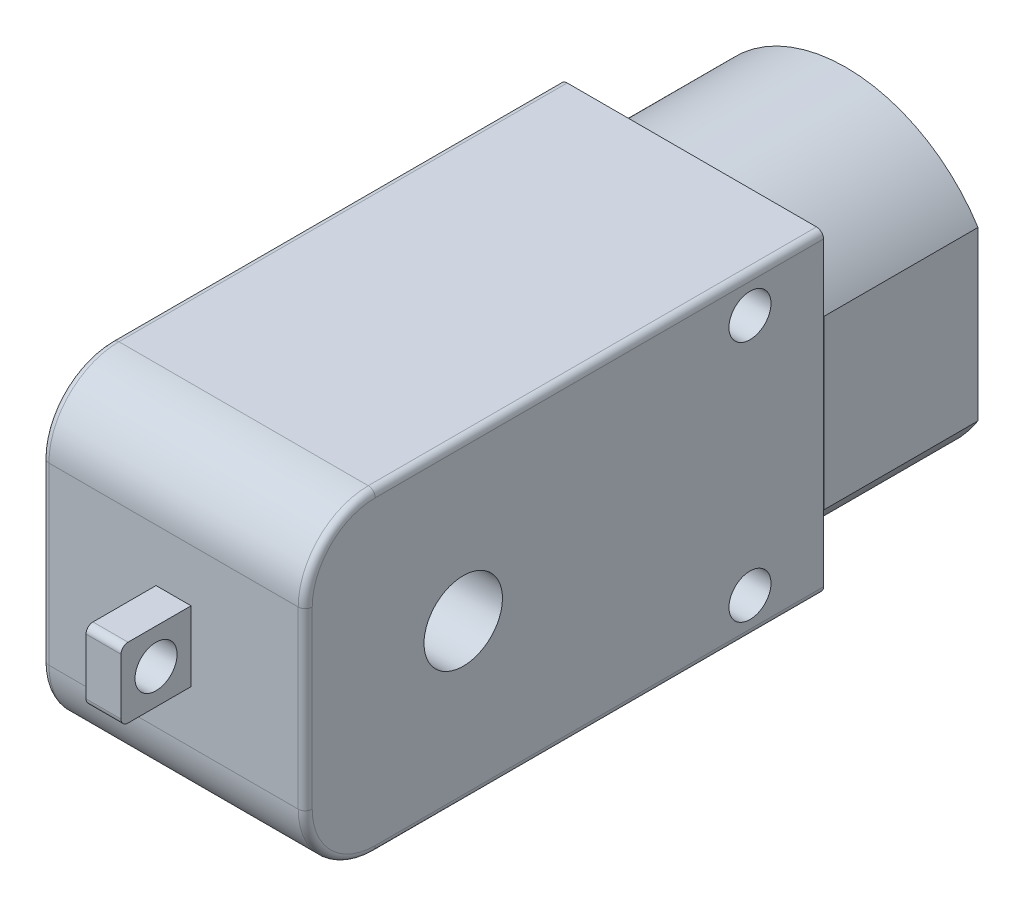
from build123d import *

# Parameters (mm, degrees)
SKETCH1_W           = 18.8
SKETCH1_H           = 22.5
BOSS_EXTRUDE1_DEPTH = 37
BOSS_EXTRUDE2_DEPTH = 11
FILLET1_R           = 5
SKETCH3_R           = 1.5
CUT_EXTRUDE1_DEPTH  = 19.8
SKETCH4_W           = 2.5
SKETCH4_H           = 5
BOSS_EXTRUDE3_DEPTH = 5
FILLET2_R           = 0.5
SKETCH5_R           = 1.5
CUT_EXTRUDE2_DEPTH  = 5
SKETCH6_R           = 2.8
CUT_EXTRUDE3_DEPTH  = 19.8
CUT_EXTRUDE4_DEPTH  = 11
SKETCH8_R           = 3
CUT_EXTRUDE5_DEPTH  = 2


with BuildPart() as part:
    # Sketch1 → Boss-Extrude1 (new body)
    with BuildSketch(Plane.XY):
        Rectangle(SKETCH1_W, SKETCH1_H)
    extrude(amount=BOSS_EXTRUDE1_DEPTH)

    # Sketch2 → Boss-Extrude2 (add)
    with BuildSketch(Plane(origin=(0, 0, 0), x_dir=(-1, 0, 0), z_dir=(0, 0, -1))):
        with BuildLine():
            Line((9.4, 6.025985397), (9.4, -6.025985397))
            ThreePointArc((9.4, -6.025985397), (-0.026782234, -11.165651916), (-9.428799853, -5.980822129))
            Line((-9.428799853, -5.980822129), (-9.428799853, 5.980822129))
            ThreePointArc((-9.428799853, 5.980822129), (-0.026782234, 11.165651916), (9.4, 6.025985397))
        make_face()
    extrude(amount=BOSS_EXTRUDE2_DEPTH)

    # Fillet1
    fillet1_edges = [part.edges().sort_by_distance(p)[0] for p in [
        (0, 11.25, 37),
        (0, -11.25, 37),
    ]]
    fillet(fillet1_edges, radius=FILLET1_R)

    # Sketch3 → Cut-Extrude1 (cut, through all)
    with BuildSketch(Plane(origin=(9.4, 0, 0), x_dir=(0, 0, -1), z_dir=(1, 0, 0))):
        with Locations((-5.25, 8.65)):
            Circle(SKETCH3_R)
        with Locations((-5.25, -8.65)):
            Circle(SKETCH3_R)
    extrude(amount=-CUT_EXTRUDE1_DEPTH, mode=Mode.SUBTRACT)

    # Sketch4 → Boss-Extrude3 (add)
    with BuildSketch(Plane.XY.offset(37)):
        Rectangle(SKETCH4_W, SKETCH4_H)
    extrude(amount=BOSS_EXTRUDE3_DEPTH)

    # Fillet2
    fillet2_edges = [part.edges().sort_by_distance(p)[0] for p in [
        (-9.4, 0, 37),
        (9.4, 0, 37),
        (9.4, 11.25, 16),
        (9.4, -11.25, 16),
        (9.4, 9.785533906, 35.535533906),
        (9.4, -9.785533906, 35.535533906),
        (-9.4, -11.25, 16),
        (-9.4, 11.25, 16),
        (-9.4, 9.785533906, 35.535533906),
        (-9.4, -9.785533906, 35.535533906),
        (0, -2.5, 42),
        (0, 2.5, 42),
    ]]
    fillet(fillet2_edges, radius=FILLET2_R)

    # Sketch5 → Cut-Extrude2 (cut)
    with BuildSketch(Plane(origin=(1.25, 0, 0), x_dir=(0, 0, -1), z_dir=(1, 0, 0))):
        with Locations((-39.5, 0)):
            Circle(SKETCH5_R)
    extrude(amount=-CUT_EXTRUDE2_DEPTH, mode=Mode.SUBTRACT)

    # Sketch6 → Cut-Extrude3 (cut, through all)
    with BuildSketch(Plane(origin=(9.4, 0, 0), x_dir=(0, 0, -1), z_dir=(1, 0, 0))):
        with Locations((-25.72, 0)):
            Circle(SKETCH6_R)
    extrude(amount=-CUT_EXTRUDE3_DEPTH, mode=Mode.SUBTRACT)

    # Sketch7 → Cut-Extrude4 (cut)
    with BuildSketch(Plane(origin=(0, 0, -11), x_dir=(-1, 0, 0), z_dir=(0, 0, -1))):
        with BuildLine():
            Line((-8.228799853, 5.62153994), (-8.228799853, -5.62153994))
            ThreePointArc((-8.228799853, -5.62153994), (-0.025432798, -9.965651584), (8.2, -5.663466987))
            Line((8.2, -5.663466987), (8.2, 5.663466987))
            ThreePointArc((8.2, 5.663466987), (-0.025432798, 9.965651584), (-8.228799853, 5.62153994))
        make_face()
    extrude(amount=-CUT_EXTRUDE4_DEPTH, mode=Mode.SUBTRACT)

    # Sketch8 → Cut-Extrude5 (cut)
    with BuildSketch(Plane(origin=(0, 0, 0), x_dir=(-1, 0, 0), z_dir=(0, 0, -1))):
        Circle(SKETCH8_R)
    extrude(amount=-CUT_EXTRUDE5_DEPTH, mode=Mode.SUBTRACT)


solid = part.part
